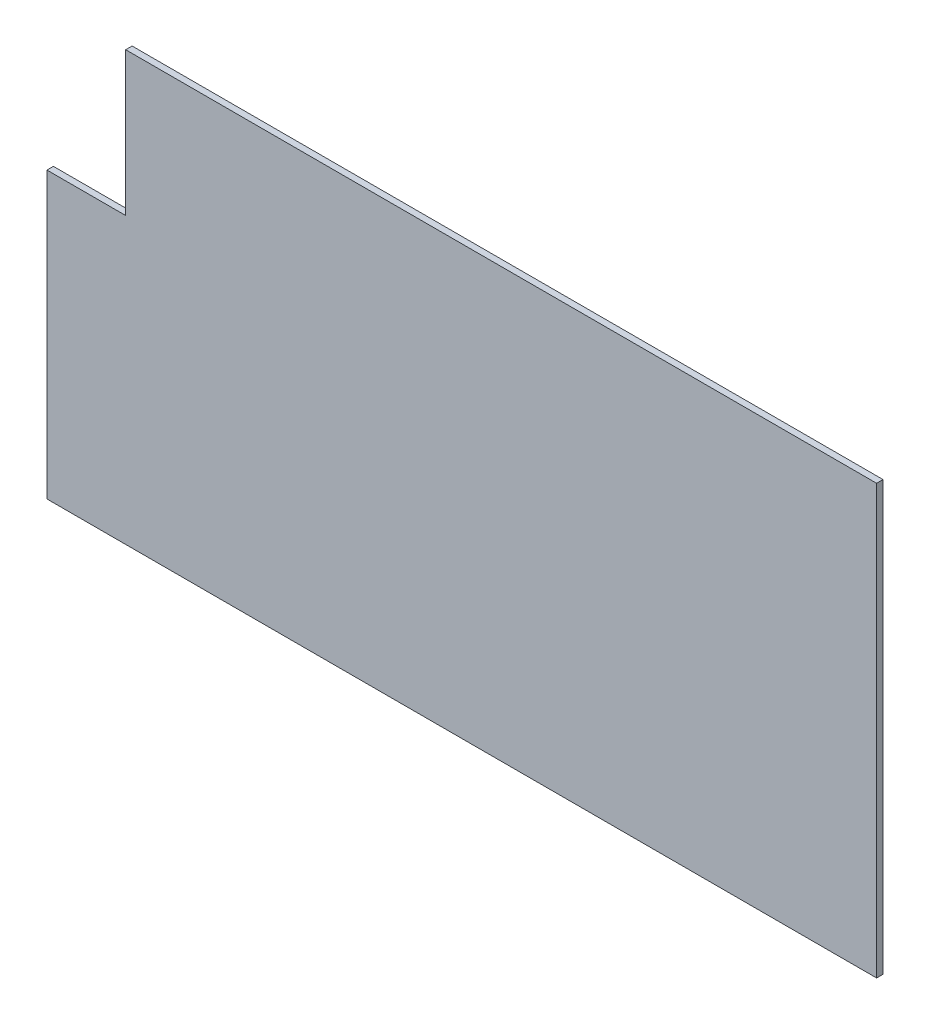
from build123d import *

# Parameters (mm, degrees)
SKETCH1_W           = 579
SKETCH1_H           = 299
BOSS_EXTRUDE1_DEPTH = 2.2479
SKETCH2_W           = 54.949993563
SKETCH2_H           = 100.2
CUT_EXTRUDE1_DEPTH  = 4.4958


with BuildPart() as part:
    # Sketch1 → Boss-Extrude1 (new body, symmetric)
    with BuildSketch(Plane.XY):
        Rectangle(SKETCH1_W, SKETCH1_H)
    extrude(amount=BOSS_EXTRUDE1_DEPTH, both=True)

    # Sketch2 → Cut-Extrude1 (cut)
    with BuildSketch(Plane(origin=(0, 0, -2.2479), x_dir=(-1, 0, 0), z_dir=(0, 0, -1))):
        with Locations((262.025003218, 99.4)):
            Rectangle(SKETCH2_W, SKETCH2_H)
    extrude(amount=-CUT_EXTRUDE1_DEPTH, mode=Mode.SUBTRACT)


solid = part.part
